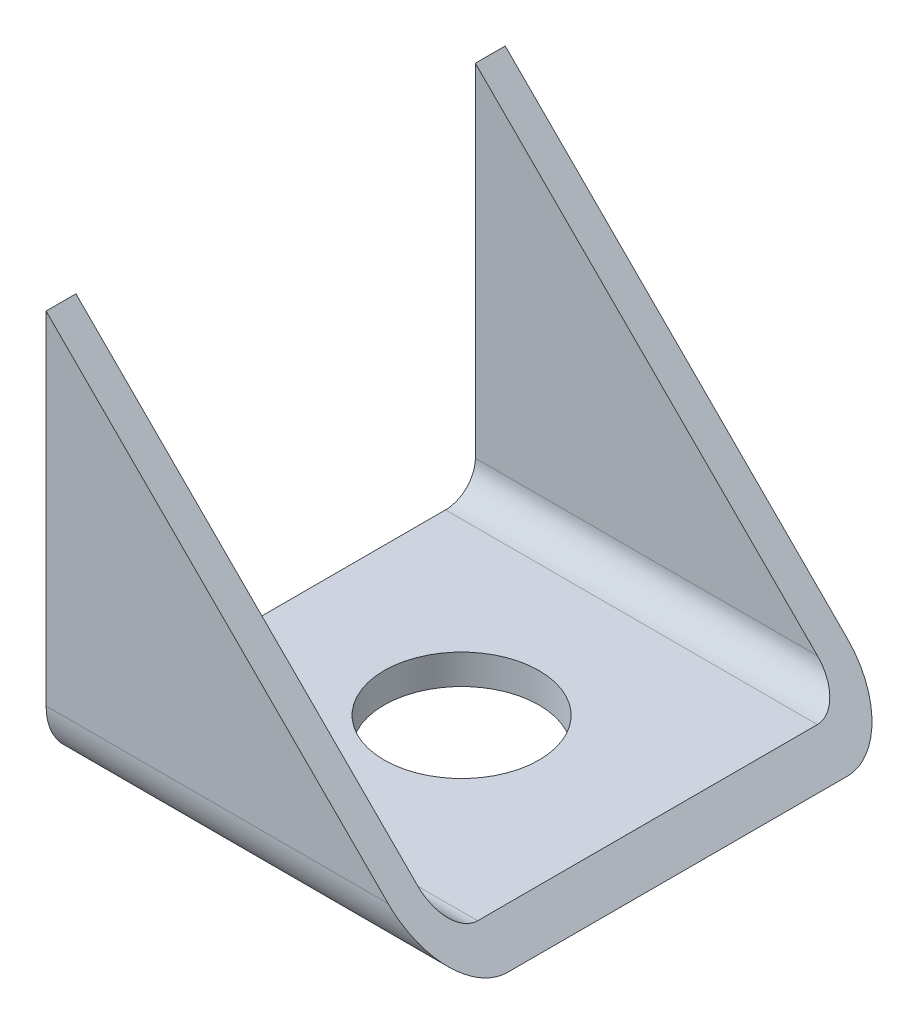
from build123d import *

# Parameters (mm, degrees)
TUBE_SQUARE_40_X_40_X_2_6_1_DEPTH = 35
CUT_EXTRUDE1_DEPTH                = 57.789083458
M12_CLEARANCE_HOLE1_D             = 13.5
M12_CLEARANCE_HOLE1_DEPTH         = 3.15
M12_CLEARANCE_HOLE1_TIP           = 4.055809178


with BuildPart() as part:
    # Sketch11 → Tube (square) 40 X 40 X 2.6(1) (new body)
    with BuildSketch(Plane.YZ):
        with BuildLine():
            Line((-14.8, -20), (14.8, -20))
            ThreePointArc((14.8, -20), (18.476955262, -18.476955262), (20, -14.8))
            Line((20, -14.8), (20, 14.8))
            ThreePointArc((20, 14.8), (18.476955262, 18.476955262), (14.8, 20))
            Line((14.8, 20), (-14.8, 20))
            ThreePointArc((-14.8, 20), (-18.476955262, 18.476955262), (-20, 14.8))
            Line((-20, 14.8), (-20, -14.8))
            ThreePointArc((-20, -14.8), (-18.476955262, -18.476955262), (-14.8, -20))
        make_face()
        with BuildLine():
            Line((-14.8, -17.4), (14.8, -17.4))
            ThreePointArc((14.8, -17.4), (16.638477631, -16.638477631), (17.4, -14.8))
            Line((17.4, -14.8), (17.4, 14.8))
            ThreePointArc((17.4, 14.8), (16.638477631, 16.638477631), (14.8, 17.4))
            Line((14.8, 17.4), (-14.8, 17.4))
            ThreePointArc((-14.8, 17.4), (-16.638477631, 16.638477631), (-17.4, 14.8))
            Line((-17.4, 14.8), (-17.4, -14.8))
            ThreePointArc((-17.4, -14.8), (-16.638477631, -16.638477631), (-14.8, -17.4))
        make_face(mode=Mode.SUBTRACT)
    extrude(amount=TUBE_SQUARE_40_X_40_X_2_6_1_DEPTH)

    # Sketch13 → Cut-Extrude1 (cut, through all)
    with BuildSketch(Plane.XY.offset(20)):
        Polygon((-5, 20), (35, -20), (35, 20), align=None)
    extrude(amount=-CUT_EXTRUDE1_DEPTH, mode=Mode.SUBTRACT)

    # M12 Clearance Hole1
    with Locations(Plane(origin=(0, -17.4, 0), x_dir=(1, 0, 0), z_dir=(0, 1, 0))):
        with Locations((16.2, 0)):
            Hole(M12_CLEARANCE_HOLE1_D / 2, depth=M12_CLEARANCE_HOLE1_DEPTH)
            with Locations((0, 0, -(M12_CLEARANCE_HOLE1_DEPTH + M12_CLEARANCE_HOLE1_TIP / 2))):  # 118° drill point
                Cone(0, M12_CLEARANCE_HOLE1_D / 2, M12_CLEARANCE_HOLE1_TIP, mode=Mode.SUBTRACT)


solid = part.part
